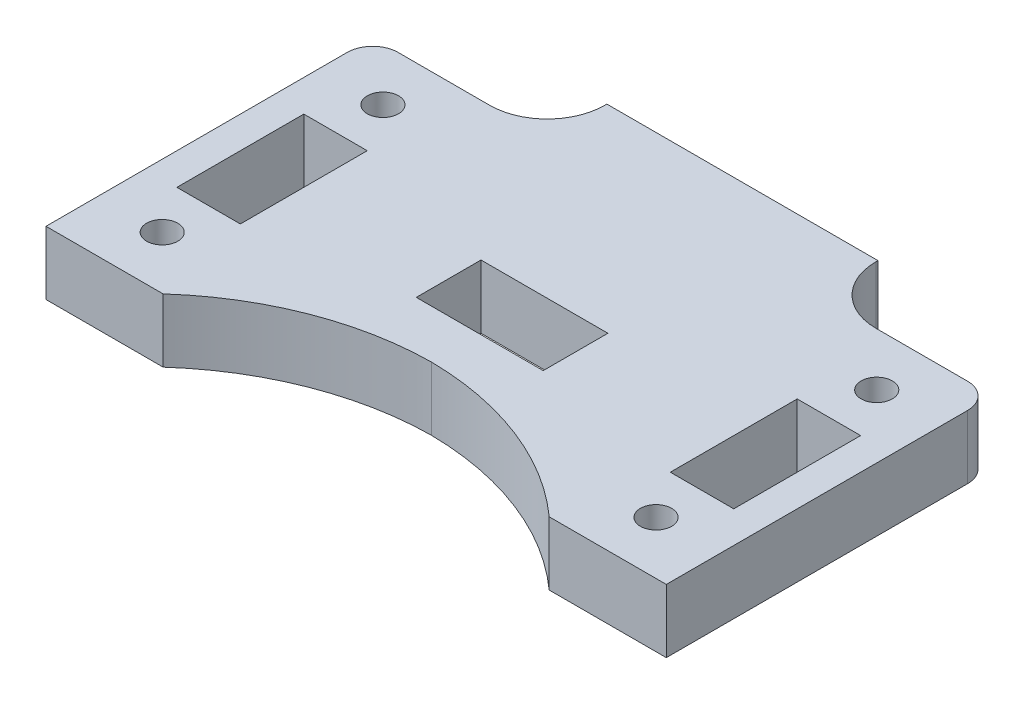
from build123d import *

# Parameters (mm, degrees)
SKETCH1_R           = 1.5621
SKETCH1_W           = 6.35
SKETCH1_H           = 12.7
SKETCH1_W_2         = 12.7
SKETCH1_H_2         = 6.477
BOSS_EXTRUDE1_DEPTH = 6.35
FILLET1_R           = 2.54
CHAMFER1_SIZE       = 1.905


with BuildPart() as part:
    # Sketch1 → Boss-Extrude1 (new body)
    with BuildSketch(Plane(origin=(0, 0, 0), x_dir=(1, 0, 0), z_dir=(0, 1, 0))):
        with BuildLine():
            Line((13.568067648, 22.312647987), (-13.568067648, 22.312647987))
            Line((-13.568067648, 22.312647987), (-13.568067648, 22.095526842))
            ThreePointArc((-13.568067648, 22.095526842), (-15.25275396, 18.028334299), (-19.319946504, 16.343647987))
            Line((-19.319946504, 16.343647987), (-31.0388, 16.343647987))
            Line((-31.0388, 16.343647987), (-31.0388, -16.343647987))
            Line((-31.0388, -16.343647987), (-29.684698321, -16.343647987))
            Line((-29.684698321, -16.343647987), (-19.319946504, -16.343647987))
            ThreePointArc((-19.319946504, -16.343647987), (-10.344922534, -10.823696712), (0, -8.822823132))
            ThreePointArc((0, -8.822823132), (10.344922534, -10.823696712), (19.319946504, -16.343647987))
            Line((19.319946504, -16.343647987), (29.684698321, -16.343647987))
            Line((29.684698321, -16.343647987), (31.0388, -16.343647987))
            Line((31.0388, -16.343647987), (31.0388, 16.343647987))
            Line((31.0388, 16.343647987), (19.319946504, 16.343647987))
            ThreePointArc((19.319946504, 16.343647987), (15.25275396, 18.028334299), (13.568067648, 22.095526842))
            Line((13.568067648, 22.095526842), (13.568067648, 22.312647987))
        make_face()
        with Locations((-24.709647151, 11.044056729)):
            Circle(SKETCH1_R, mode=Mode.SUBTRACT)
        with Locations((-24.709647151, -11.044056729)):
            Circle(SKETCH1_R, mode=Mode.SUBTRACT)
        with Locations((24.709647151, 11.044056729)):
            Circle(SKETCH1_R, mode=Mode.SUBTRACT)
        with Locations((24.709647151, -11.044056729)):
            Circle(SKETCH1_R, mode=Mode.SUBTRACT)
        with Locations((24.6888, -0.068443271)):
            Rectangle(SKETCH1_W, SKETCH1_H, mode=Mode.SUBTRACT)
        with Locations((-24.6888, -0.068443271)):
            Rectangle(SKETCH1_W, SKETCH1_H, mode=Mode.SUBTRACT)
        with Locations((0, -0.737852013)):
            Rectangle(SKETCH1_W_2, SKETCH1_H_2, mode=Mode.SUBTRACT)
    extrude(amount=BOSS_EXTRUDE1_DEPTH)

    # Fillet1
    fillet1_edges = [part.edges().sort_by_distance(p)[0] for p in [
        (-31.0388, 3.175, -16.343647987),
        (31.0388, 3.175, -16.343647987),
    ]]
    fillet(fillet1_edges, radius=FILLET1_R)

    # Chamfer1
    chamfer1_edges = [part.edges().sort_by_distance(p)[0] for p in [
        (-26.271747151, 0, -11.044056729),
        (-26.271747151, 0, 11.044056729),
        (23.147547151, 0, -11.044056729),
        (23.147547151, 0, 11.044056729),
    ]]
    chamfer(chamfer1_edges, length=CHAMFER1_SIZE)


solid = part.part
